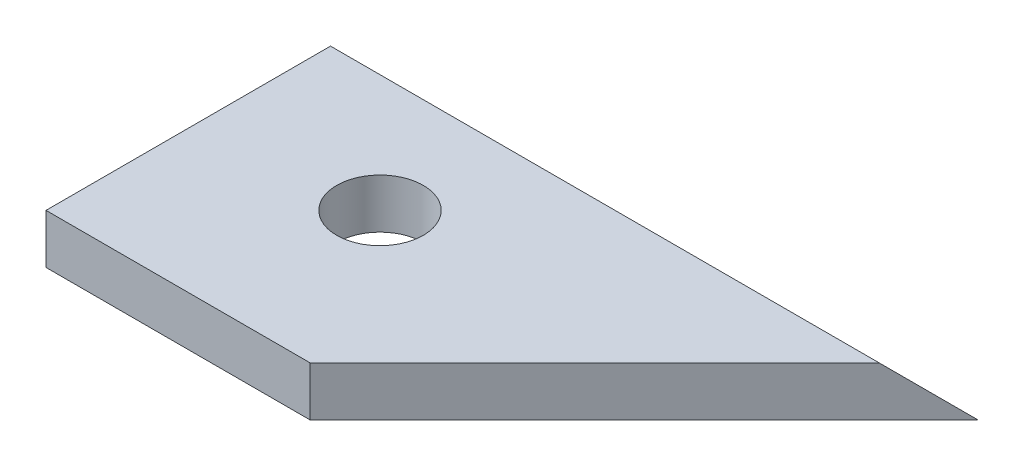
from build123d import *

# Parameters (mm, degrees)
SKETCH1_R           = 7
BOSS_EXTRUDE1_DEPTH = 8
CUT_EXTRUDE4_START  = -42.686292
CUT_EXTRUDE4_DEPTH  = 192


with BuildPart() as part:
    # Sketch1 → Boss-Extrude1 (new body)
    with BuildSketch(Plane(origin=(0, 0, 0), x_dir=(1, 0, 0), z_dir=(0, 1, 0))):
        Polygon((0, -21.713615023), (54, 32.286384977), (11.313708499, 32.286384977), (-42.686291501, 32.286384977), (-42.686291501, -21.713615023), align=None)
        with Locations((-15.686291501, 5.286384977)):
            Circle(SKETCH1_R, mode=Mode.SUBTRACT)
    extrude(amount=BOSS_EXTRUDE1_DEPTH)

    # Sketch4 → Cut-Extrude4 (cut)
    with BuildSketch(Plane(origin=(0, 0, 0), x_dir=(0, 0, -1), z_dir=(1, 0, 0)).offset(CUT_EXTRUDE4_START)):
        Polygon((32.286384977, 0), (24.286384977, 8), (32.286384977, 8), align=None)
    extrude(amount=CUT_EXTRUDE4_DEPTH, mode=Mode.SUBTRACT)


solid = part.part
